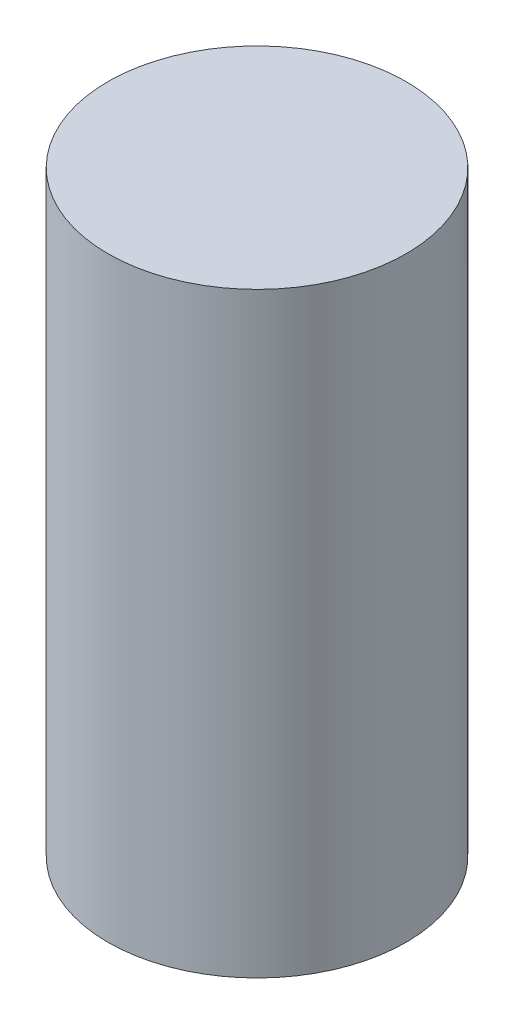
from build123d import *

# Parameters (mm, degrees)
SKETCH1_R           = 100
BOSS_EXTRUDE1_DEPTH = 400


with BuildPart() as part:
    # Sketch1 → Boss-Extrude1 (new body)
    with BuildSketch(Plane(origin=(0, 0, 0), x_dir=(1, 0, 0), z_dir=(0, 1, 0))):
        Circle(SKETCH1_R)
    extrude(amount=BOSS_EXTRUDE1_DEPTH)


solid = part.part
